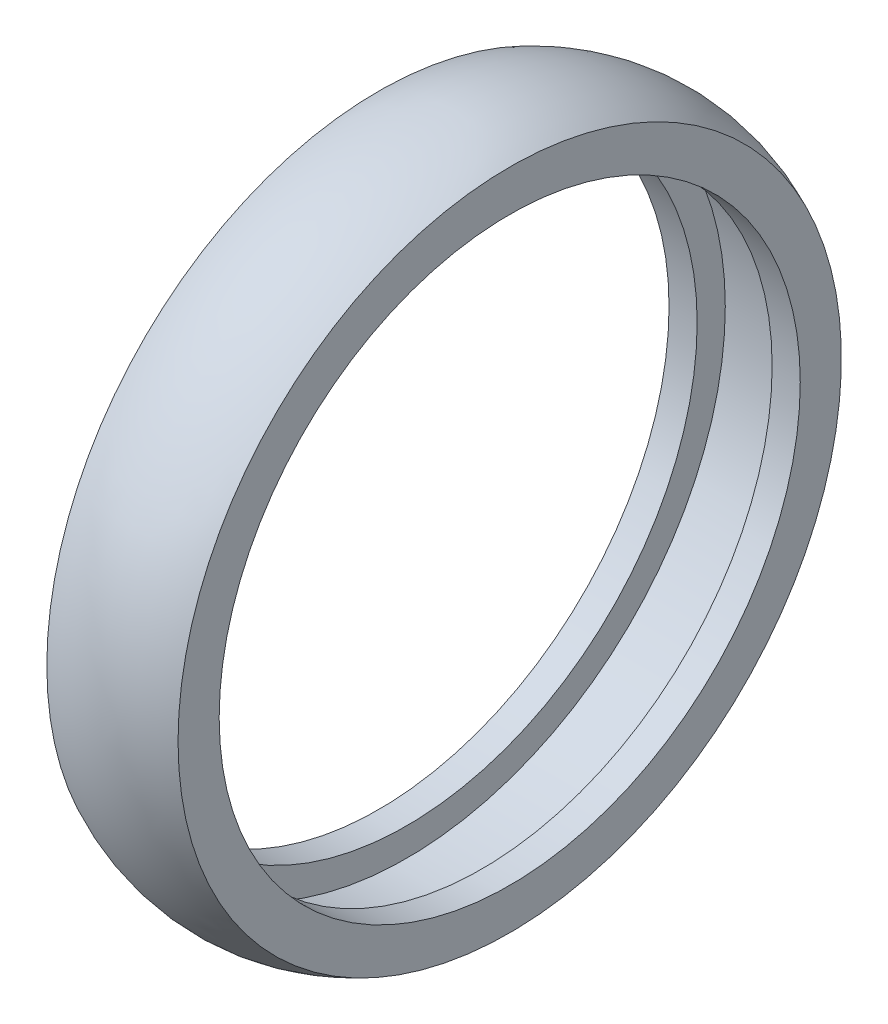
from build123d import *


with BuildPart() as part:
    # Sketch1 → Revolve1 (revolve)
    with BuildSketch(Plane.XY):
        with BuildLine():
            Line((4, 34), (-4, 34))
            Line((-4, 34), (-4, 31))
            Line((-4, 31), (-7, 31))
            Line((-7, 31), (-7, 35.38749457))
            ThreePointArc((-7, 35.38749457), (0, 37), (7, 35.38749457))
            Line((7, 35.38749457), (7, 31))
            Line((7, 31), (4, 31))
            Line((4, 31), (4, 34))
        make_face()
    revolve(axis=Axis((-690.466838324, 0, 0), (1, 0, 0)))


solid = part.part
